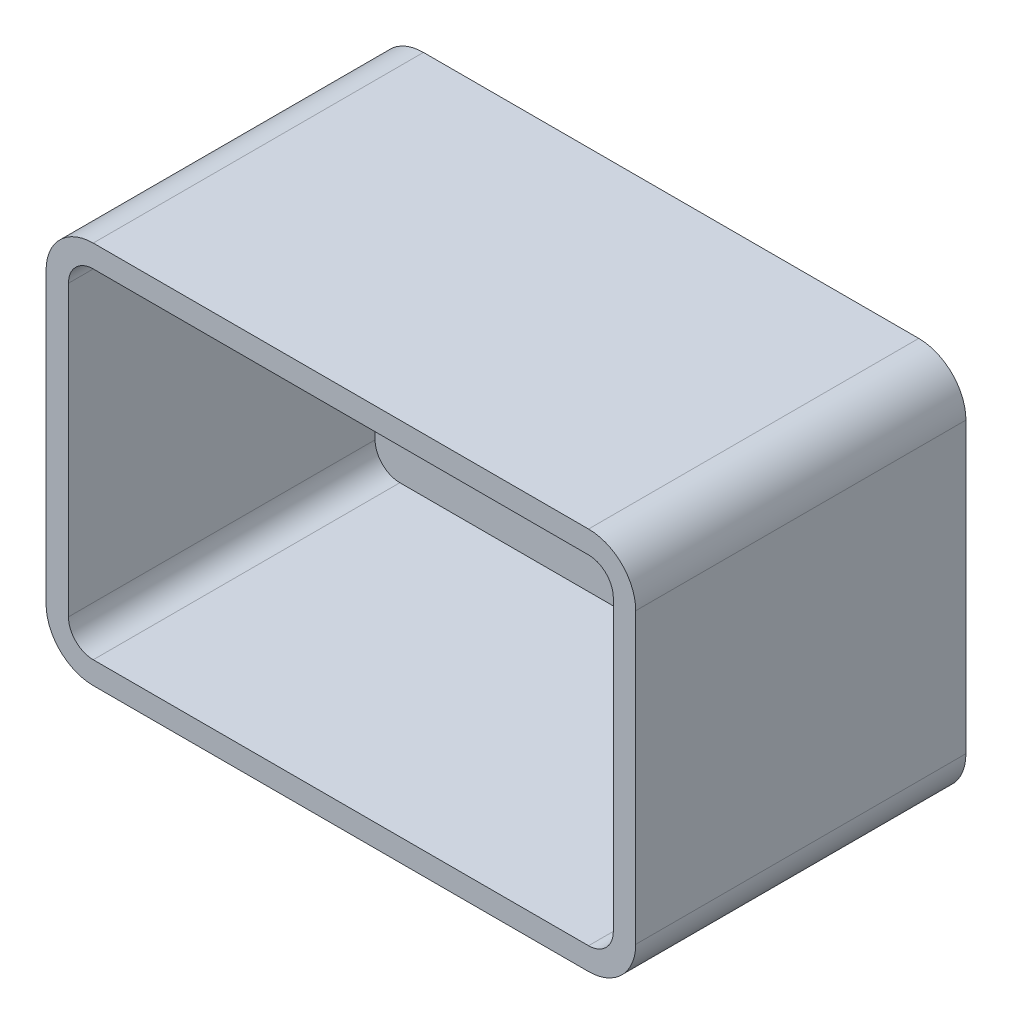
from build123d import *

# Parameters (mm, degrees)
BOSS_EXTRUDE1_DEPTH = 28
BOSS_EXTRUDE2_DEPTH = 2


with BuildPart() as part:
    # Sketch1 → Boss-Extrude1 (new body)
    with BuildSketch(Plane.XY):
        with BuildLine():
            ThreePointArc((-25, -12.25), (-23.828427125, -15.078427125), (-21, -16.25))
            Line((-21, -16.25), (21, -16.25))
            ThreePointArc((21, -16.25), (23.828427125, -15.078427125), (25, -12.25))
            Line((25, -12.25), (25, 12.25))
            ThreePointArc((25, 12.25), (23.828427125, 15.078427125), (21, 16.25))
            Line((21, 16.25), (-21, 16.25))
            ThreePointArc((-21, 16.25), (-23.828427125, 15.078427125), (-25, 12.25))
            Line((-25, 12.25), (-25, -12.25))
        make_face()
        with BuildLine():
            ThreePointArc((-23.1, 12.25), (-22.48492424, 13.73492424), (-21, 14.35))
            Line((-21, 14.35), (21, 14.35))
            ThreePointArc((21, 14.35), (22.48492424, 13.73492424), (23.1, 12.25))
            Line((23.1, 12.25), (23.1, -12.25))
            ThreePointArc((23.1, -12.25), (22.48492424, -13.73492424), (21, -14.35))
            Line((21, -14.35), (-21, -14.35))
            ThreePointArc((-21, -14.35), (-22.48492424, -13.73492424), (-23.1, -12.25))
            Line((-23.1, -12.25), (-23.1, 12.25))
        make_face(mode=Mode.SUBTRACT)
    extrude(amount=BOSS_EXTRUDE1_DEPTH)

    # Sketch1_3 → Boss-Extrude2 (add)
    with BuildSketch(Plane.XY):
        with BuildLine():
            Line((21, 14.35), (-21, 14.35))
            ThreePointArc((-21, 14.35), (-22.48492424, 13.73492424), (-23.1, 12.25))
            Line((-23.1, 12.25), (-23.1, -12.25))
            ThreePointArc((-23.1, -12.25), (-22.48492424, -13.73492424), (-21, -14.35))
            Line((-21, -14.35), (21, -14.35))
            ThreePointArc((21, -14.35), (22.48492424, -13.73492424), (23.1, -12.25))
            Line((23.1, -12.25), (23.1, 12.25))
            ThreePointArc((23.1, 12.25), (22.48492424, 13.73492424), (21, 14.35))
        make_face()
        with BuildLine():
            Line((-14.5, -9), (-19.5, -9))
            ThreePointArc((-19.5, -9), (-20.207106781, -8.707106781), (-20.5, -8))
            Line((-20.5, -8), (-20.5, 8))
            ThreePointArc((-20.5, 8), (-20.207106781, 8.707106781), (-19.5, 9))
            Line((-19.5, 9), (-14.5, 9))
            ThreePointArc((-14.5, 9), (-13.792893219, 8.707106781), (-13.5, 8))
            Line((-13.5, 8), (-13.5, -8))
            ThreePointArc((-13.5, -8), (-13.792893219, -8.707106781), (-14.5, -9))
        make_face(mode=Mode.SUBTRACT)
    extrude(amount=BOSS_EXTRUDE2_DEPTH)


solid = part.part
